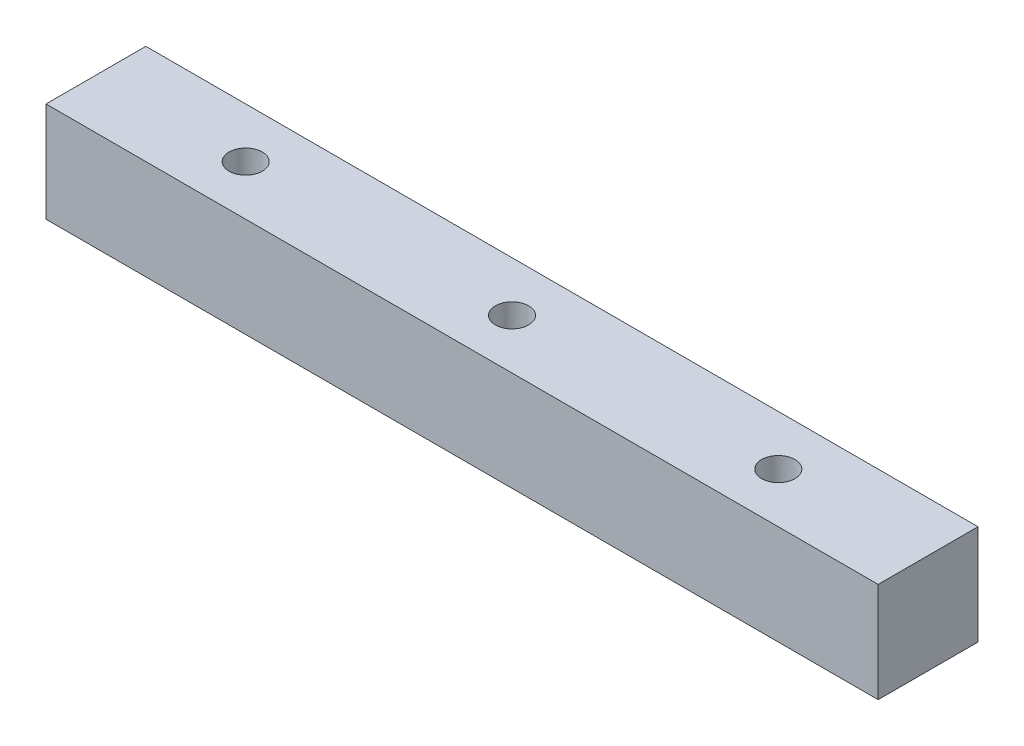
from build123d import *

# Parameters (mm, degrees)
SKETCH_1_W          = 25
SKETCH_1_H          = 3
EXTRUDE_1_DEPTH     = 3
SKETCH_2_R          = 0.5
CUT_EXTRUDE_1_DEPTH = 4


with BuildPart() as part:
    # 草图1 → 凸台-拉伸1 (new body)
    with BuildSketch(Plane(origin=(0, 0, 0), x_dir=(1, 0, 0), z_dir=(0, 1, 0))):
        Rectangle(SKETCH_1_W, SKETCH_1_H)
    extrude(amount=EXTRUDE_1_DEPTH)

    # 草图2 → 切除-拉伸1 (cut, through all)
    with BuildSketch(Plane(origin=(0, 3, 0), x_dir=(1, 0, 0), z_dir=(0, 1, 0))):
        with Locations((-8, 0)):
            Circle(SKETCH_2_R)
        Circle(SKETCH_2_R)
        with Locations((8, 0)):
            Circle(SKETCH_2_R)
    extrude(amount=-CUT_EXTRUDE_1_DEPTH, mode=Mode.SUBTRACT)


solid = part.part
